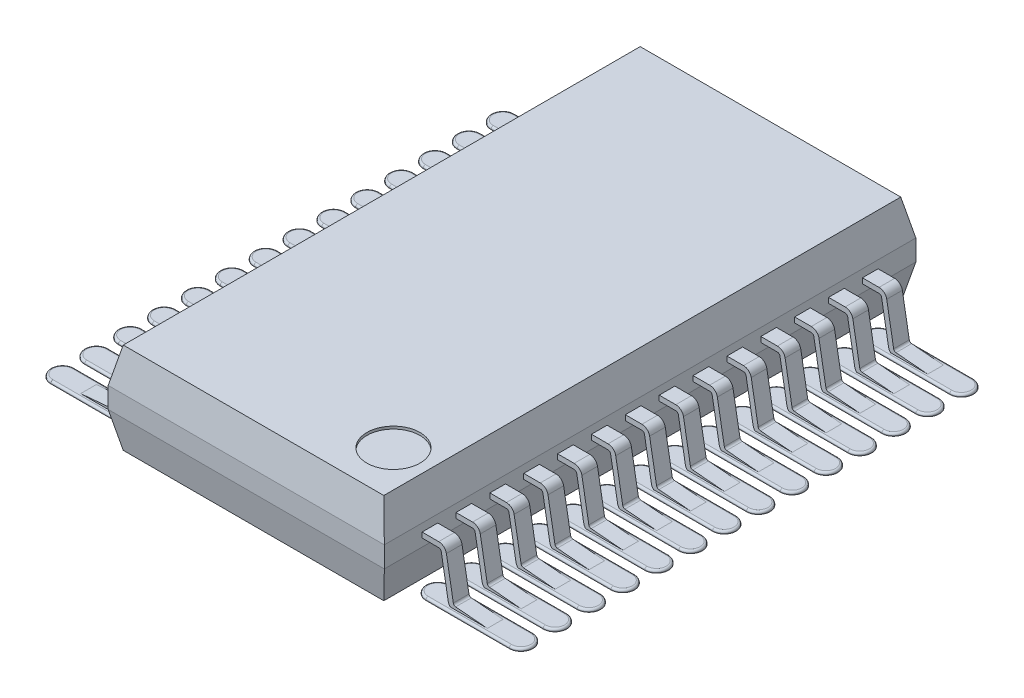
from build123d import *

# Parameters (mm, degrees)
BOSS_EXTRUDE1_DEPTH     = 5.1
CUT_EXTRUDE2_DEPTH      = 3.65
CUT_EXTRUDE2_DEPTH_BACK = 3.65
EXTRUDE_THIN1_DEPTH     = 0.15
BOSS_EXTRUDE2_DEPTH     = 0.05
FILLET1_R               = 0.04
LPATTERN1_COUNT         = 14
LPATTERN1_PITCH         = 0.65
FILLET1_OF_LPATTERN1_R  = 0.04
SKETCH3_R               = 0.51
CUT_EXTRUDE1_DEPTH      = 0.05


with BuildPart() as part:
    # Sketch1 → Boss-Extrude1 (new body, symmetric)
    with BuildSketch(Plane.XY):
        Polygon((-2.5, 1.85), (2.5, 1.85), (2.65, 1.175), (2.65, 0.775), (2.5, 0.1), (-2.5, 0.1), (-2.65, 0.775), (-2.65, 1.175), align=None)
    extrude(amount=BOSS_EXTRUDE1_DEPTH, both=True)

    # Sketch4 → Cut-Extrude2 (cut, two sides)
    with BuildSketch(Plane(origin=(0, 0, 0), x_dir=(0, 0, -1), z_dir=(1, 0, 0))) as cut_extrude2_sk:
        Polygon((-4.96, 1.85), (-5.1, 1.175), (-5.1, 0.775), (-4.96, 0.1), (-5.16, 0.1), (-5.16, 1.85), align=None)
        Polygon((5.1, 1.175), (4.96, 1.85), (5.16, 1.85), (5.16, 0.1), (4.96, 0.1), (5.1, 0.775), align=None)
    extrude(amount=CUT_EXTRUDE2_DEPTH, mode=Mode.SUBTRACT)
    extrude(cut_extrude2_sk.sketch, amount=-CUT_EXTRUDE2_DEPTH_BACK, mode=Mode.SUBTRACT)

    # Sketch2 → Extrude-Thin1 (add, symmetric)
    with BuildSketch(Plane.XY.offset(4.225)):
        with BuildLine():
            Line((-3.895642213, -0.049809735), (-3.285407414, 0.003578892))
            ThreePointArc((-3.285407414, 0.003578892), (-3.197142244, 0.042416496), (-3.150759612, 0.12696087))
            Line((-3.150759612, 0.12696087), (-3.017329188, 0.883682409))
            ThreePointArc((-3.017329188, 0.883682409), (-3.000228181, 0.913302222), (-2.968088801, 0.925))
            Line((-2.968088801, 0.925), (2.968088801, 0.925))
            ThreePointArc((2.968088801, 0.925), (3.000228181, 0.913302222), (3.017329188, 0.883682409))
            Line((3.017329188, 0.883682409), (3.150759612, 0.12696087))
            ThreePointArc((3.150759612, 0.12696087), (3.197142244, 0.042416496), (3.285407414, 0.003578892))
            Line((3.285407414, 0.003578892), (3.895642213, -0.049809735))
            Line((3.895642213, -0.049809735), (3.904357787, 0.049809735))
            Line((3.904357787, 0.049809735), (3.294122988, 0.103198362))
            ThreePointArc((3.294122988, 0.103198362), (3.264701265, 0.11614423), (3.249240388, 0.144325688))
            Line((3.249240388, 0.144325688), (3.115809963, 0.901047227))
            ThreePointArc((3.115809963, 0.901047227), (3.064506942, 0.989906666), (2.968088801, 1.025))
            Line((2.968088801, 1.025), (-2.968088801, 1.025))
            ThreePointArc((-2.968088801, 1.025), (-3.064506942, 0.989906666), (-3.115809963, 0.901047227))
            Line((-3.115809963, 0.901047227), (-3.249240388, 0.144325688))
            ThreePointArc((-3.249240388, 0.144325688), (-3.264701265, 0.11614423), (-3.294122988, 0.103198362))
            Line((-3.294122988, 0.103198362), (-3.904357787, 0.049809735))
            Line((-3.904357787, 0.049809735), (-3.895642213, -0.049809735))
        make_face()
    extrude_thin1 = extrude(amount=EXTRUDE_THIN1_DEPTH, both=True)

    # Sketch5 → Boss-Extrude2 (add)
    with BuildSketch(Plane(origin=(0, 0, 0), x_dir=(1, 0, 0), z_dir=(0, 1, 0))):
        with BuildLine():
            Line((-2.8, -4.45), (-4.4, -4.45))
            ThreePointArc((-4.4, -4.45), (-4.625, -4.225), (-4.4, -4))
            Line((-4.4, -4), (-2.8, -4))
            ThreePointArc((-2.8, -4), (-2.575, -4.225), (-2.8, -4.45))
        make_face()
        with BuildLine():
            Line((2.8, -4), (4.4, -4))
            ThreePointArc((4.4, -4), (4.625, -4.225), (4.4, -4.45))
            Line((4.4, -4.45), (2.8, -4.45))
            ThreePointArc((2.8, -4.45), (2.575, -4.225), (2.8, -4))
        make_face()
    boss_extrude2 = extrude(amount=BOSS_EXTRUDE2_DEPTH)

    # Fillet1
    fillet1_edges = [part.edges().sort_by_distance(p)[0] for p in [
        (-2.575, 0.05, 4.225),
        (-3.6, 0.05, 4),
        (-4.625, 0.05, 4.225),
        (-3.6, 0.05, 4.45),
        (2.575, 0.05, 4.225),
        (3.6, 0.05, 4.45),
        (4.625, 0.05, 4.225),
        (3.6, 0.05, 4),
    ]]
    fillet(fillet1_edges, radius=FILLET1_R)

    # LPattern1: Extrude-Thin1, Boss-Extrude2 ×14
    with Locations(*[(0, 0, -i * LPATTERN1_PITCH) for i in range(1, LPATTERN1_COUNT)]):
        add(extrude_thin1)
        add(boss_extrude2)

    # Fillet1 of LPattern1
    fillet1_of_lpattern1_edges = [part.edges().sort_by_distance(p)[0] for p in [
        (-2.575, 0.05, 3.575),
        (-3.6, 0.05, 3.35),
        (-4.625, 0.05, 3.575),
        (-3.6, 0.05, 3.8),
        (2.575, 0.05, 3.575),
        (3.6, 0.05, 3.8),
        (4.625, 0.05, 3.575),
        (3.6, 0.05, 3.35),
        (-2.575, 0.05, 2.925),
        (-3.6, 0.05, 2.7),
        (-4.625, 0.05, 2.925),
        (-3.6, 0.05, 3.15),
        (2.575, 0.05, 2.925),
        (3.6, 0.05, 3.15),
        (4.625, 0.05, 2.925),
        (3.6, 0.05, 2.7),
        (-2.575, 0.05, 2.275),
        (-3.6, 0.05, 2.05),
        (-4.625, 0.05, 2.275),
        (-3.6, 0.05, 2.5),
        (2.575, 0.05, 2.275),
        (3.6, 0.05, 2.5),
        (4.625, 0.05, 2.275),
        (3.6, 0.05, 2.05),
        (-2.575, 0.05, 1.625),
        (-3.6, 0.05, 1.4),
        (-4.625, 0.05, 1.625),
        (-3.6, 0.05, 1.85),
        (2.575, 0.05, 1.625),
        (3.6, 0.05, 1.85),
        (4.625, 0.05, 1.625),
        (3.6, 0.05, 1.4),
        (-2.575, 0.05, 0.975),
        (-3.6, 0.05, 0.75),
        (-4.625, 0.05, 0.975),
        (-3.6, 0.05, 1.2),
        (2.575, 0.05, 0.975),
        (3.6, 0.05, 1.2),
        (4.625, 0.05, 0.975),
        (3.6, 0.05, 0.75),
        (-2.575, 0.05, 0.325),
        (-3.6, 0.05, 0.1),
        (-4.625, 0.05, 0.325),
        (-3.6, 0.05, 0.55),
        (2.575, 0.05, 0.325),
        (3.6, 0.05, 0.55),
        (4.625, 0.05, 0.325),
        (3.6, 0.05, 0.1),
        (-2.575, 0.05, -0.325),
        (-3.6, 0.05, -0.55),
        (-4.625, 0.05, -0.325),
        (-3.6, 0.05, -0.1),
        (2.575, 0.05, -0.325),
        (3.6, 0.05, -0.1),
        (4.625, 0.05, -0.325),
        (3.6, 0.05, -0.55),
        (-2.575, 0.05, -0.975),
        (-3.6, 0.05, -1.2),
        (-4.625, 0.05, -0.975),
        (-3.6, 0.05, -0.75),
        (2.575, 0.05, -0.975),
        (3.6, 0.05, -0.75),
        (4.625, 0.05, -0.975),
        (3.6, 0.05, -1.2),
        (-2.575, 0.05, -1.625),
        (-3.6, 0.05, -1.85),
        (-4.625, 0.05, -1.625),
        (-3.6, 0.05, -1.4),
        (2.575, 0.05, -1.625),
        (3.6, 0.05, -1.4),
        (4.625, 0.05, -1.625),
        (3.6, 0.05, -1.85),
        (-2.575, 0.05, -2.275),
        (-3.6, 0.05, -2.5),
        (-4.625, 0.05, -2.275),
        (-3.6, 0.05, -2.05),
        (2.575, 0.05, -2.275),
        (3.6, 0.05, -2.05),
        (4.625, 0.05, -2.275),
        (3.6, 0.05, -2.5),
        (-2.575, 0.05, -2.925),
        (-3.6, 0.05, -3.15),
        (-4.625, 0.05, -2.925),
        (-3.6, 0.05, -2.7),
        (2.575, 0.05, -2.925),
        (3.6, 0.05, -2.7),
        (4.625, 0.05, -2.925),
        (3.6, 0.05, -3.15),
        (-2.575, 0.05, -3.575),
        (-3.6, 0.05, -3.8),
        (-4.625, 0.05, -3.575),
        (-3.6, 0.05, -3.35),
        (2.575, 0.05, -3.575),
        (3.6, 0.05, -3.35),
        (4.625, 0.05, -3.575),
        (3.6, 0.05, -3.8),
        (-2.575, 0.05, -4.225),
        (-3.6, 0.05, -4.45),
        (-4.625, 0.05, -4.225),
        (-3.6, 0.05, -4),
        (2.575, 0.05, -4.225),
        (3.6, 0.05, -4),
        (4.625, 0.05, -4.225),
        (3.6, 0.05, -4.45),
    ]]
    fillet(fillet1_of_lpattern1_edges, radius=FILLET1_OF_LPATTERN1_R)

    # Sketch3 → Cut-Extrude1 (cut)
    with BuildSketch(Plane(origin=(0, 1.85, 0), x_dir=(-1, 0, 0), z_dir=(0, 1, 0))):
        with Locations((-1.8, 4.075)):
            Circle(SKETCH3_R)
    extrude(amount=-CUT_EXTRUDE1_DEPTH, mode=Mode.SUBTRACT)


solid = part.part
